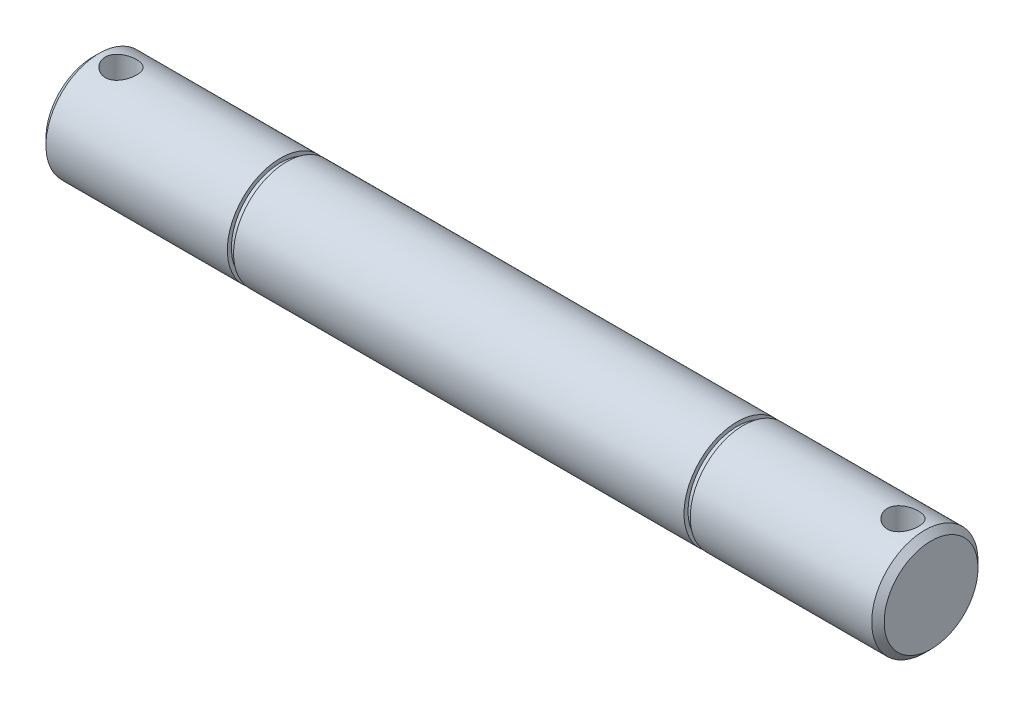
from build123d import *

# Parameters (mm, degrees)
SKETCH1_R               = 8.5
BOSS_EXTRUDE1_DEPTH     = 134
CHAMFER1_SIZE           = 1
SKETCH2_R               = 2.5
CUT_EXTRUDE1_DEPTH      = 9.5
CUT_EXTRUDE1_DEPTH_BACK = 9.5
SKETCH3_R               = 8.5
SKETCH3_R_2             = 7.85
CUT_EXTRUDE2_DEPTH      = 1


with BuildPart() as part:
    # Sketch1 → Boss-Extrude1 (new body)
    with BuildSketch(Plane(origin=(0, 0, 0), x_dir=(0, 0, -1), z_dir=(1, 0, 0))):
        Circle(SKETCH1_R)
    extrude(amount=BOSS_EXTRUDE1_DEPTH)

    # Chamfer1
    chamfer1_edges = [part.edges().sort_by_distance(p)[0] for p in [
        (0, 0, 8.5),
        (134, 0, 8.5),
    ]]
    chamfer(chamfer1_edges, length=CHAMFER1_SIZE)

    # Sketch2 → Cut-Extrude1 (cut, two sides)
    with BuildSketch(Plane(origin=(0, 0, 0), x_dir=(1, 0, 0), z_dir=(0, 1, 0))) as cut_extrude1_sk:
        with Locations((4.5, 0)):
            Circle(SKETCH2_R)
        with Locations((129.5, 0)):
            Circle(SKETCH2_R)
    extrude(amount=CUT_EXTRUDE1_DEPTH, mode=Mode.SUBTRACT)
    extrude(cut_extrude1_sk.sketch, amount=-CUT_EXTRUDE1_DEPTH_BACK, mode=Mode.SUBTRACT)

    # Sketch3 → Cut-Extrude2 (cut)
    with BuildSketch(Plane(origin=(104, 0, 0), x_dir=(0, 0, -1), z_dir=(1, 0, 0))):
        Circle(SKETCH3_R)
        Circle(SKETCH3_R_2, mode=Mode.SUBTRACT)
    cut_extrude2 = extrude(amount=-CUT_EXTRUDE2_DEPTH, mode=Mode.SUBTRACT)

    # Mirror1: Cut-Extrude2 across plane
    add(cut_extrude2.mirror(Plane(origin=(67, 0, 0), x_dir=(0, 0, 1), z_dir=(1, 0, 0))), mode=Mode.SUBTRACT)


solid = part.part
